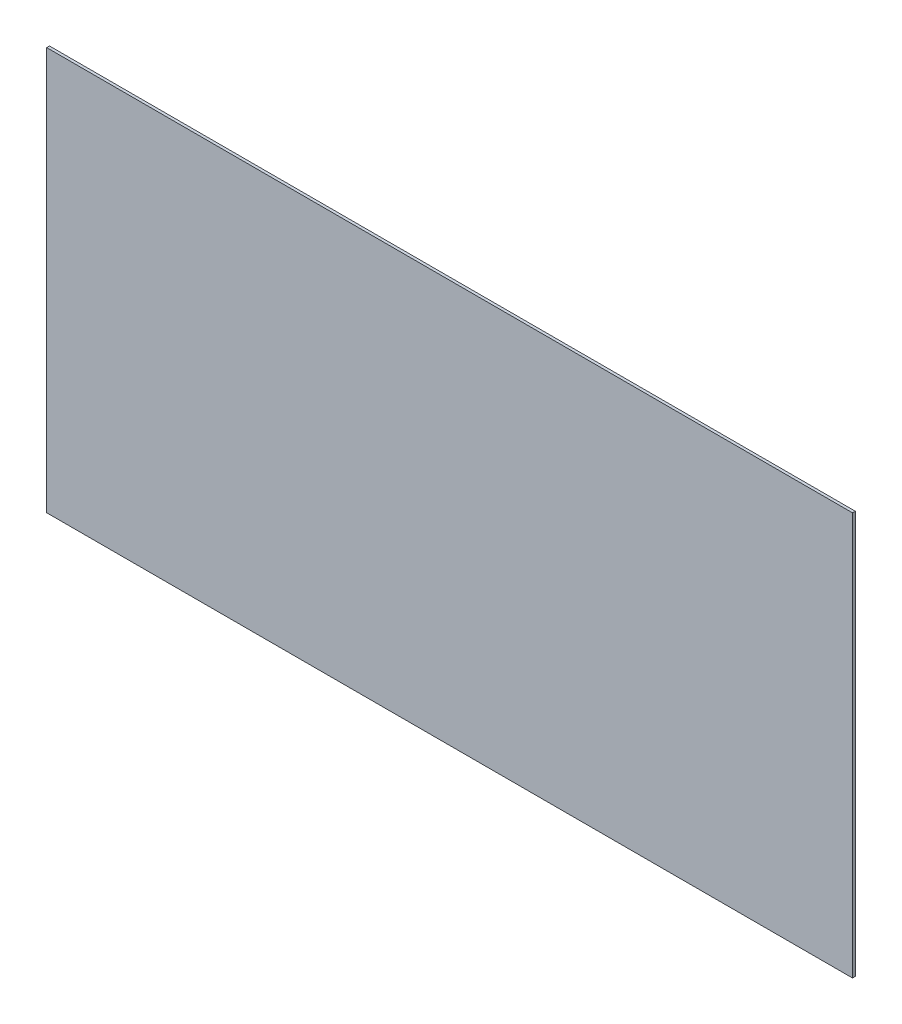
from build123d import *

# Parameters (mm, degrees)
SKETCH1_W           = 914.4
SKETCH1_H           = 457.2
BOSS_EXTRUDE1_DEPTH = 3.175


with BuildPart() as part:
    # Sketch1 → Boss-Extrude1 (new body)
    with BuildSketch(Plane.XY):
        with Locations((0, 228.6)):
            Rectangle(SKETCH1_W, SKETCH1_H)
    extrude(amount=-BOSS_EXTRUDE1_DEPTH)


solid = part.part
